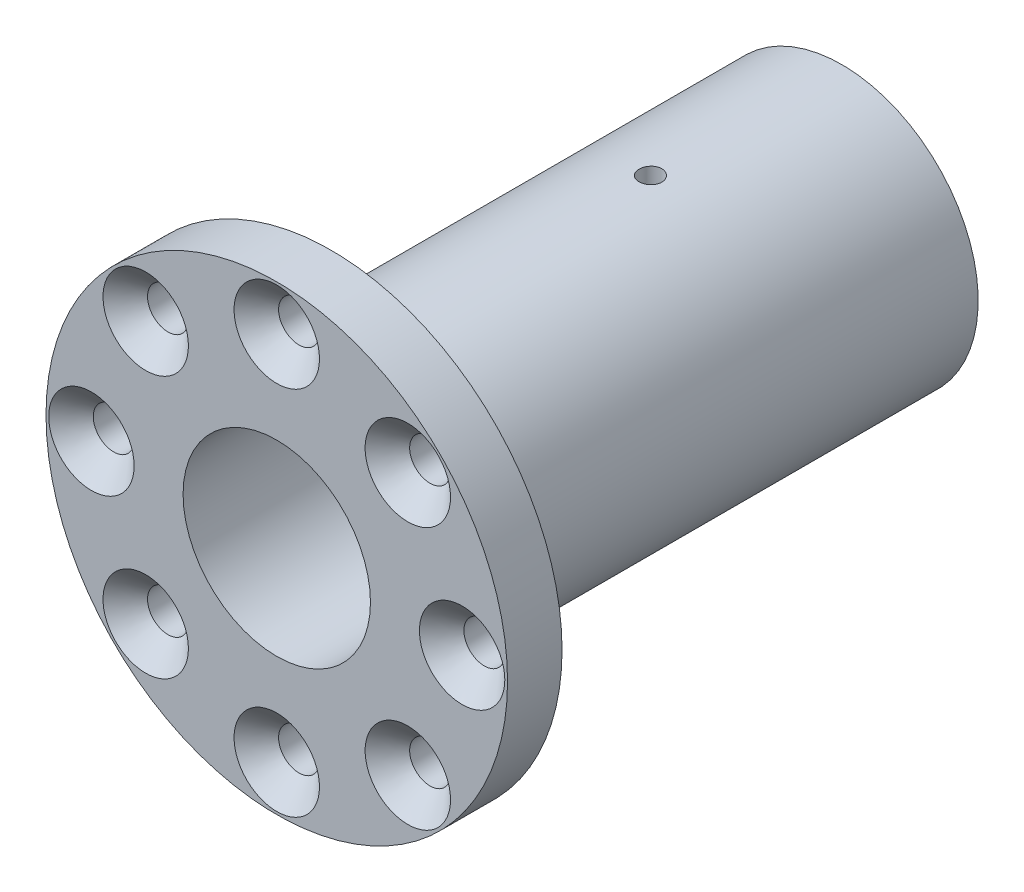
from build123d import *

# Parameters (mm, degrees)
SKETCH1_W                                         = 25.4
SKETCH1_H                                         = 6
SKETCH2_R                                         = 15
BOSS_EXTRUDE1_DEPTH                               = 56.2
CUT_EXTRUDE1_DEPTH                                = 63.2
SKETCH4_W                                         = 7.0104
SKETCH4_H                                         = 65.418639441
F_2_CLEARANCE_HOLE1_D                             = 2.5
F_2_CLEARANCE_HOLE1_DEPTH                         = 12
SKETCH7_W                                         = 1.25
SKETCH7_H                                         = 16.341500105
CSK_FOR_8_FLAT_HEAD_MACHINE_SCREW_100_D           = 4.5
CSK_FOR_8_FLAT_HEAD_MACHINE_SCREW_100_DEPTH       = 62.2
CSK_FOR_8_FLAT_HEAD_MACHINE_SCREW_100_CSINK_D     = 9.4
CSK_FOR_8_FLAT_HEAD_MACHINE_SCREW_100_CSINK_ANGLE = 90
SKETCH11_R                                        = 10.3124
CUT_EXTRUDE2_DEPTH                                = 38.1


with BuildPart() as part:
    # Sketch1 → Revolve1 (revolve)
    with BuildSketch(Plane.XZ):
        with Locations((12.7, 58.54)):
            Rectangle(SKETCH1_W, SKETCH1_H)
    revolve(axis=Axis((0, 0, 61.54), (0, 0, -1)))

    # Sketch2 → Boss-Extrude1 (add)
    with BuildSketch(Plane(origin=(0, 0, 55.54), x_dir=(-1, 0, 0), z_dir=(0, 0, -1))):
        Circle(SKETCH2_R)
    extrude(amount=BOSS_EXTRUDE1_DEPTH)

    # Sketch3 → Cut-Extrude1 (cut, through all)
    with BuildSketch(Plane(origin=(0, 0, -0.66), x_dir=(-1, 0, 0), z_dir=(0, 0, -1))):
        with BuildLine():
            Line((2.5, 9.058499895), (-2.5, 9.058499895))
            Line((-2.5, 9.058499895), (-2.5, 6.538348415))
            ThreePointArc((-2.5, 6.538348415), (0, 7), (2.5, 6.538348415))
            Line((2.5, 6.538348415), (2.5, 9.058499895))
        make_face()
    extrude(amount=-CUT_EXTRUDE1_DEPTH, mode=Mode.SUBTRACT)

    # Sketch4 → Cut-Revolve1 (revolve, cut)
    with BuildSketch(Plane.XZ):
        with Locations((3.5052, 28.83068028)):
            Rectangle(SKETCH4_W, SKETCH4_H)
    revolve(axis=Axis((0, 0, 61.54), (0, 0, -1)), mode=Mode.SUBTRACT)

    # #2 Clearance Hole1
    with Locations(Plane(origin=(0, 0, -0.66), x_dir=(-1, 0, 0), z_dir=(0, 0, -1))):
        with Locations((-11.5, 0), (-5.75, -9.959292144), (5.75, -9.959292144), (11.5, 0), (5.75, 9.959292144), (-5.75, 9.959292144)):
            Hole(F_2_CLEARANCE_HOLE1_D / 2, depth=F_2_CLEARANCE_HOLE1_DEPTH)

    # Sketch7 → #2 Clearance Hole2 (revolve, cut)
    with BuildSketch(Plane(origin=(0, 9.058499895, 20.422), x_dir=(0, 0, -1), z_dir=(1, 0, 0))):
        with Locations((0.625, 8.170750053)):
            Rectangle(SKETCH7_W, SKETCH7_H)
    revolve(axis=Axis((0, 2.708499895, 20.422), (0, 1, 0)), mode=Mode.SUBTRACT)

    # CSK for #8 Flat Head Machine Screw (100)1
    with Locations(Plane.XY.offset(61.54)):
        with Locations((0, 20.4), (14.424978336, 14.424978336), (20.4, 0), (14.424978336, -14.424978336), (0, -20.4), (-14.424978336, -14.424978336), (-20.4, 0), (-14.424978336, 14.424978336)):
            CounterSinkHole(CSK_FOR_8_FLAT_HEAD_MACHINE_SCREW_100_D / 2, CSK_FOR_8_FLAT_HEAD_MACHINE_SCREW_100_CSINK_D / 2, depth=CSK_FOR_8_FLAT_HEAD_MACHINE_SCREW_100_DEPTH, counter_sink_angle=CSK_FOR_8_FLAT_HEAD_MACHINE_SCREW_100_CSINK_ANGLE)

    # Sketch11 → Cut-Extrude2 (cut)
    with BuildSketch(Plane.XY.offset(61.54)):
        Circle(SKETCH11_R)
    extrude(amount=-CUT_EXTRUDE2_DEPTH, mode=Mode.SUBTRACT)


solid = part.part
